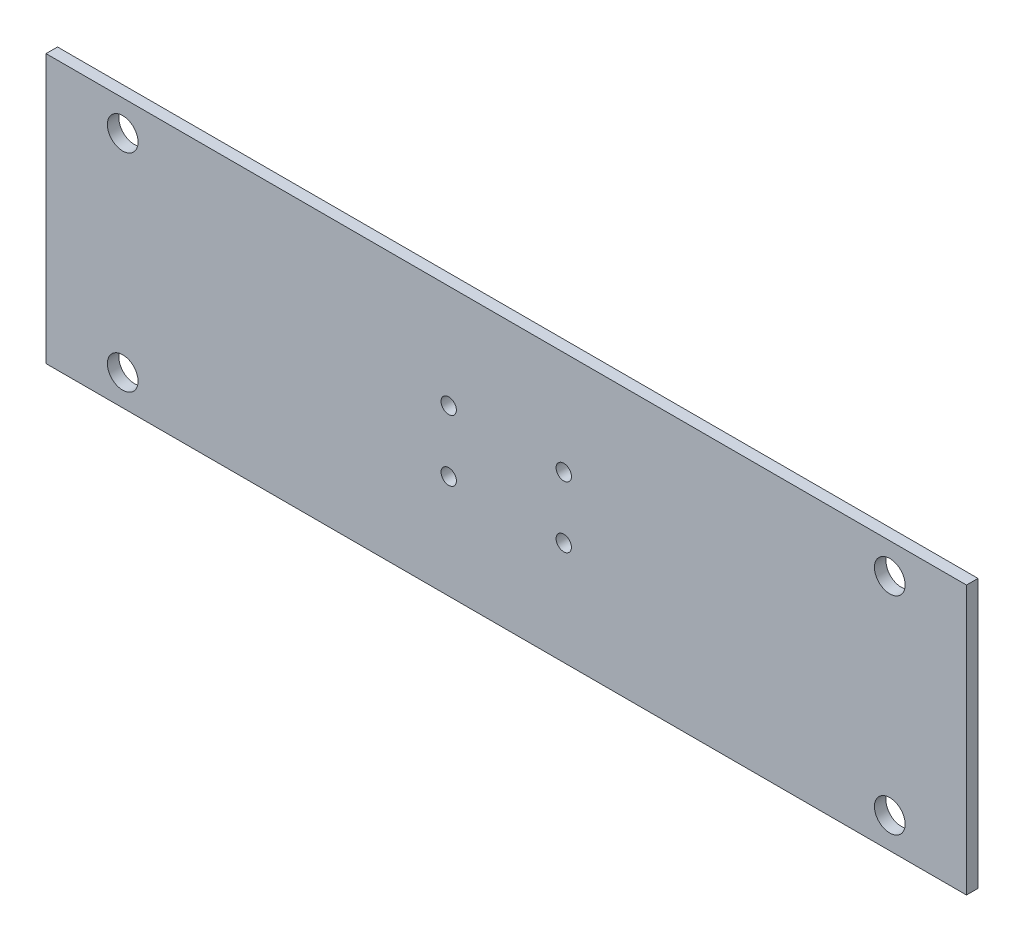
from build123d import *

# Parameters (mm, degrees)
SKETCH1_W           = 240
SKETCH1_H           = 70
SKETCH1_R           = 4
SKETCH1_R_2         = 2
BOSS_EXTRUDE1_DEPTH = 3


with BuildPart() as part:
    # Sketch1 → Boss-Extrude1 (new body)
    with BuildSketch(Plane.XY):
        Rectangle(SKETCH1_W, SKETCH1_H)
        with Locations((-100, 27)):
            Circle(SKETCH1_R, mode=Mode.SUBTRACT)
        with Locations((100, 27)):
            Circle(SKETCH1_R, mode=Mode.SUBTRACT)
        with Locations((100, -27)):
            Circle(SKETCH1_R, mode=Mode.SUBTRACT)
        with Locations((-100, -27)):
            Circle(SKETCH1_R, mode=Mode.SUBTRACT)
        with Locations((-15, 8)):
            Circle(SKETCH1_R_2, mode=Mode.SUBTRACT)
        with Locations((15, 8)):
            Circle(SKETCH1_R_2, mode=Mode.SUBTRACT)
        with Locations((15, -8)):
            Circle(SKETCH1_R_2, mode=Mode.SUBTRACT)
        with Locations((-15, -8)):
            Circle(SKETCH1_R_2, mode=Mode.SUBTRACT)
    extrude(amount=BOSS_EXTRUDE1_DEPTH)


solid = part.part
